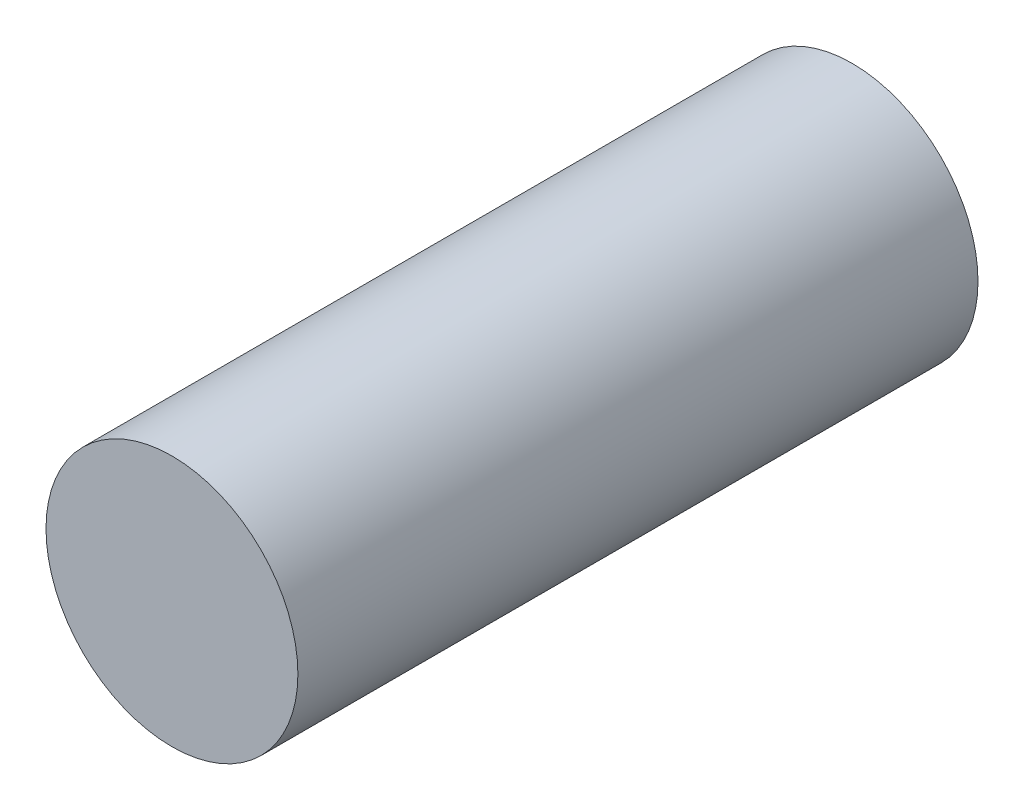
from build123d import *

# Parameters (mm, degrees)
SKETCH2_R           = 6.35
BOSS_EXTRUDE1_DEPTH = 34.29


with BuildPart() as part:
    # Sketch2 → Boss-Extrude1 (new body)
    with BuildSketch(Plane.XY):
        Circle(SKETCH2_R)
    extrude(amount=BOSS_EXTRUDE1_DEPTH)


solid = part.part
